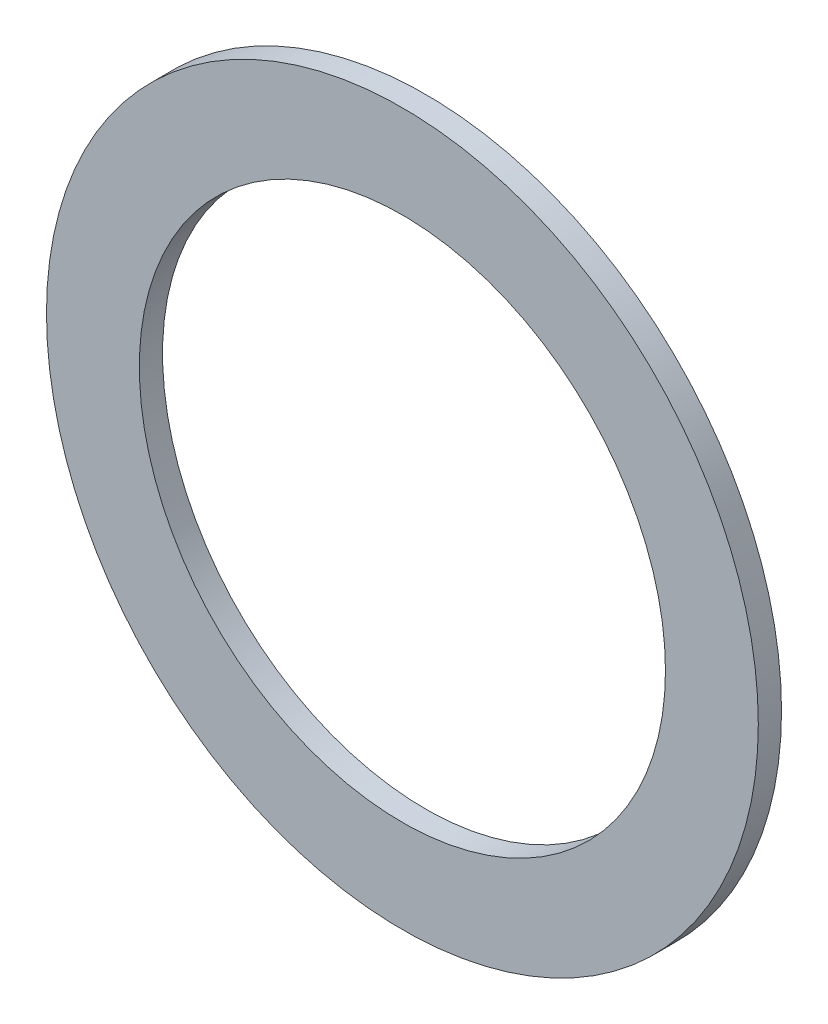
from build123d import *

# Parameters (mm, degrees)
SKETCH_1_R      = 23
SKETCH_1_R_2    = 17
EXTRUDE_1_DEPTH = 1.5


with BuildPart() as part:
    # Эскиз1 → Бобышка-Вытянуть1 (new body)
    with BuildSketch(Plane.XY):
        Circle(SKETCH_1_R)
        Circle(SKETCH_1_R_2, mode=Mode.SUBTRACT)
    extrude(amount=EXTRUDE_1_DEPTH)


solid = part.part
